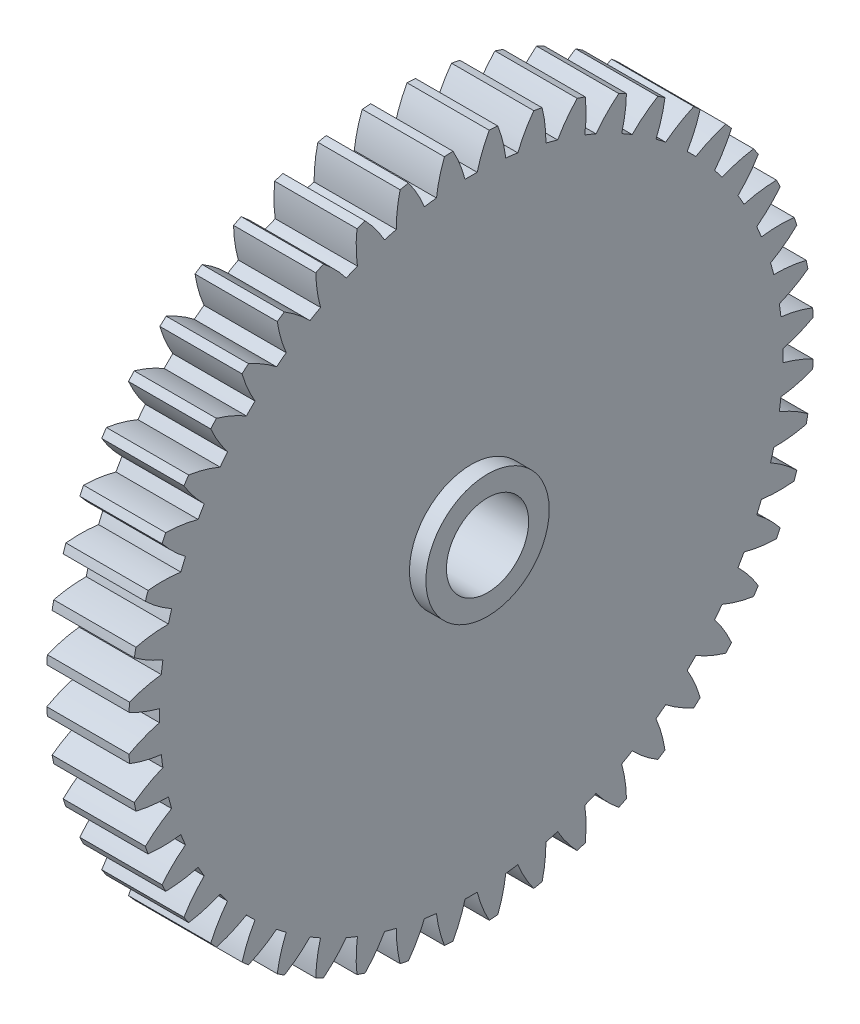
from build123d import *

# Parameters (mm, degrees)
BASPROSKE_W         = 12.7
BASPROSKE_H         = 52.916666667
TOOTHCUT_DEPTH      = 76.905449226
TEETHCUTS_COUNT     = 48
TEETHCUTS_ANGLE     = 352.5
BORSKE_R            = 6.35
BORE_DEPTH          = 50.8000508
BOSS_EXTRUDE1_START = 2.54
SKETCH1_R           = 9.525
SKETCH1_R_2         = 6.35
BOSS_EXTRUDE1_DEPTH = 2.54


with BuildPart() as part:
    # BasProSke → Base-Revolve (revolve)
    with BuildSketch(Plane(origin=(0, 0, 0), x_dir=(1, 0, 0), z_dir=(0, 1, 0)), mode=Mode.PRIVATE) as base_revolve_sk:
        with Locations((6.35, 26.458333334)):
            Rectangle(BASPROSKE_W, BASPROSKE_H)
    revolve(base_revolve_sk.sketch.rotate(Axis((-10, 0, 0), (1, 0, 0)), 180), axis=Axis((-10, 0, 0), (1, 0, 0)))

    # TooCutSke → ToothCut (cut, through all)
    with BuildSketch(Plane(origin=(0, 0, 0), x_dir=(0, 0, -1), z_dir=(1, 0, 0))):
        with BuildLine():
            ThreePointArc((0.938681533, 48.143746576), (0, 48.152896667), (-0.938681533, 48.143746576))
            ThreePointArc((-0.938681533, 48.143746576), (-1.729356878, 50.56436869), (-2.816577529, 52.86709103))
            ThreePointArc((-2.816577529, 52.86709103), (0, 52.942066667), (2.816577529, 52.86709103))
            ThreePointArc((2.816577529, 52.86709103), (1.729356878, 50.56436869), (0.938681533, 48.143746576))
        make_face()
    toothcut = extrude(amount=TOOTHCUT_DEPTH, mode=Mode.SUBTRACT)

    # TeethCuts: ToothCut ×48 about axis
    teethcuts_axis = Axis((-10, 0, 0), (1, 0, 0))
    for i in range(1, TEETHCUTS_COUNT):
        add(toothcut.rotate(teethcuts_axis, i * TEETHCUTS_ANGLE / (TEETHCUTS_COUNT - 1)), mode=Mode.SUBTRACT)

    # BorSke → Bore (cut, symmetric)
    with BuildSketch(Plane(origin=(0, 0, 0), x_dir=(0, 0, -1), z_dir=(1, 0, 0))):
        with Locations(Location((0, 0, 0), (0, 0, 180))):
            Circle(BORSKE_R)
    extrude(amount=BORE_DEPTH, both=True, mode=Mode.SUBTRACT)

    # Sketch1 → Boss-Extrude1 (add)
    with BuildSketch(Plane(origin=(12.7, 0, 0), x_dir=(0, 0, -1), z_dir=(1, 0, 0)).offset(BOSS_EXTRUDE1_START)):
        with Locations(Location((0, 0, 0), (0, 0, 180))):
            Circle(SKETCH1_R)
        Circle(SKETCH1_R_2, mode=Mode.SUBTRACT)
    extrude(amount=-BOSS_EXTRUDE1_DEPTH)


solid = part.part
